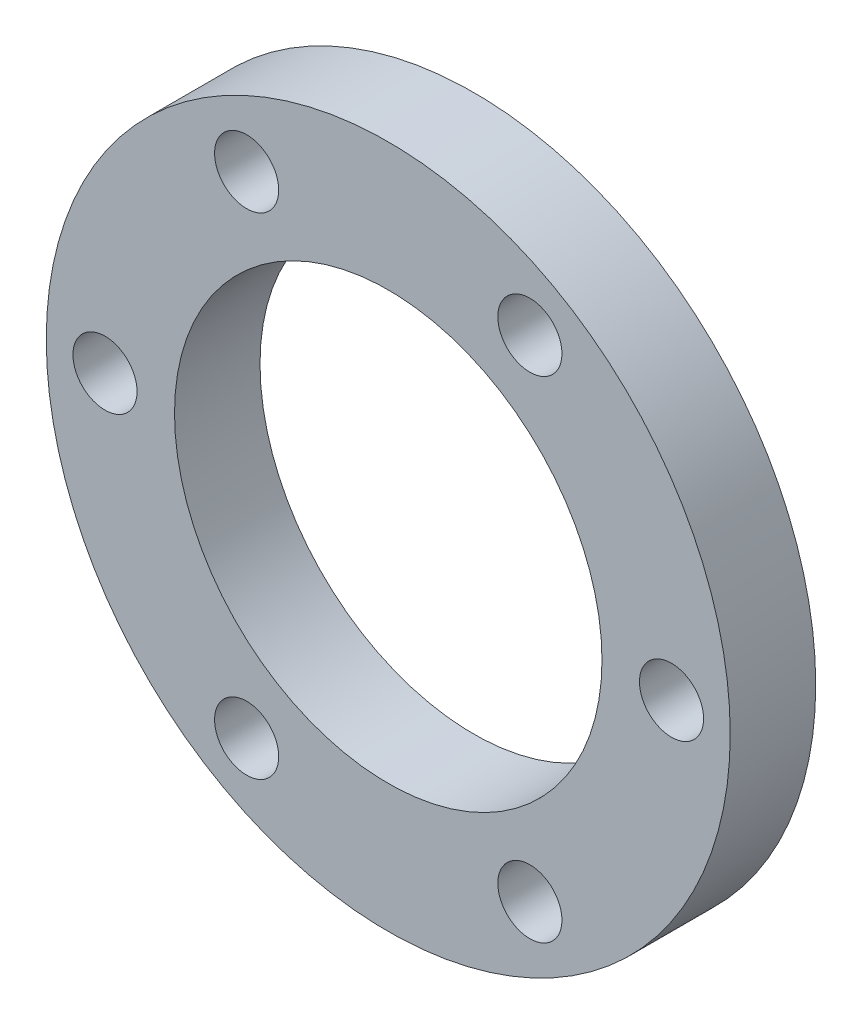
from build123d import *

# Parameters (mm, degrees)
SKETCH2_R           = 80
SKETCH2_R_2         = 50
SKETCH2_R_3         = 7.5
BOSS_EXTRUDE3_DEPTH = 20


with BuildPart() as part:
    # Sketch2 → Boss-Extrude3 (new body)
    with BuildSketch(Plane.XY):
        Circle(SKETCH2_R)
        Circle(SKETCH2_R_2, mode=Mode.SUBTRACT)
        with Locations((-66.260500731, 0)):
            Circle(SKETCH2_R_3, mode=Mode.SUBTRACT)
        with Locations((-33.130250365, 57.3832769)):
            Circle(SKETCH2_R_3, mode=Mode.SUBTRACT)
        with Locations((33.130250365, 57.3832769)):
            Circle(SKETCH2_R_3, mode=Mode.SUBTRACT)
        with Locations((66.260500731, 0)):
            Circle(SKETCH2_R_3, mode=Mode.SUBTRACT)
        with Locations((33.130250365, -57.3832769)):
            Circle(SKETCH2_R_3, mode=Mode.SUBTRACT)
        with Locations((-33.130250365, -57.3832769)):
            Circle(SKETCH2_R_3, mode=Mode.SUBTRACT)
    extrude(amount=BOSS_EXTRUDE3_DEPTH)


solid = part.part
